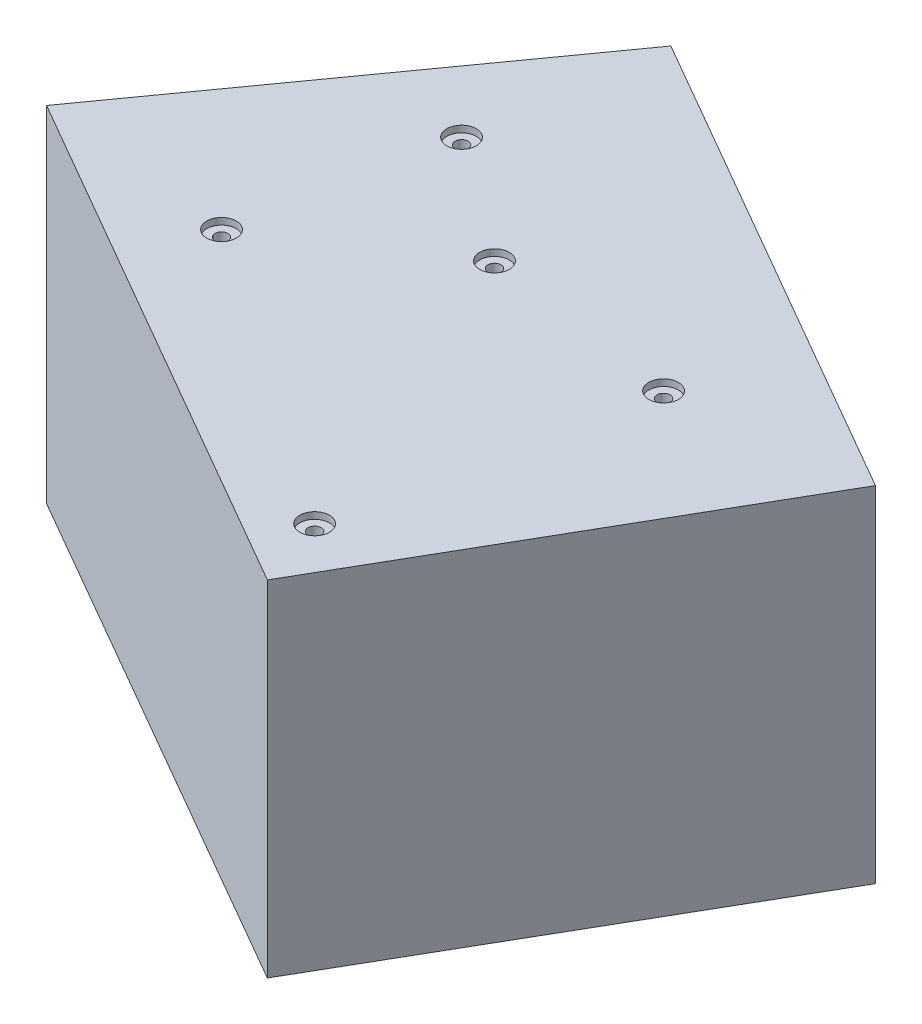
from build123d import *

# Parameters (mm, degrees)
BOSS_EXTRUDE1_DEPTH                                 = 37
CBORE_FOR_00_BINDING_HEAD_MACHINE_SCREW_D           = 1.397
CBORE_FOR_00_BINDING_HEAD_MACHINE_SCREW_CBORE_D     = 3.175
CBORE_FOR_00_BINDING_HEAD_MACHINE_SCREW_CBORE_DEPTH = 0.7112


with BuildPart() as part:
    # Sketch1 → Boss-Extrude1 (new body)
    with BuildSketch(Plane(origin=(0, 0, 0), x_dir=(1, 0, 0), z_dir=(0, 1, 0))):
        Polygon((-10.505392469, 53.079063556), (-38.479053813, 14.047908535), (17.468268874, -18.201203232), (20.541085549, -12.870331878), (41.33210383, 23.198934685), align=None)
    extrude(amount=BOSS_EXTRUDE1_DEPTH)

    # CBORE for #00 Binding Head Machine Screw1 (through all)
    with Locations(Plane(origin=(0, 37, 0), x_dir=(1, 0, 0), z_dir=(0, 1, 0))):
        with Locations((14.7823041, -10.442137487), (0, 23.641654167), (21.162859004, 20.630300354), (-17.558591277, 11.907077475), (-13.254255948, 33.366792883)):
            CounterBoreHole(CBORE_FOR_00_BINDING_HEAD_MACHINE_SCREW_D / 2, CBORE_FOR_00_BINDING_HEAD_MACHINE_SCREW_CBORE_D / 2, CBORE_FOR_00_BINDING_HEAD_MACHINE_SCREW_CBORE_DEPTH)


solid = part.part
